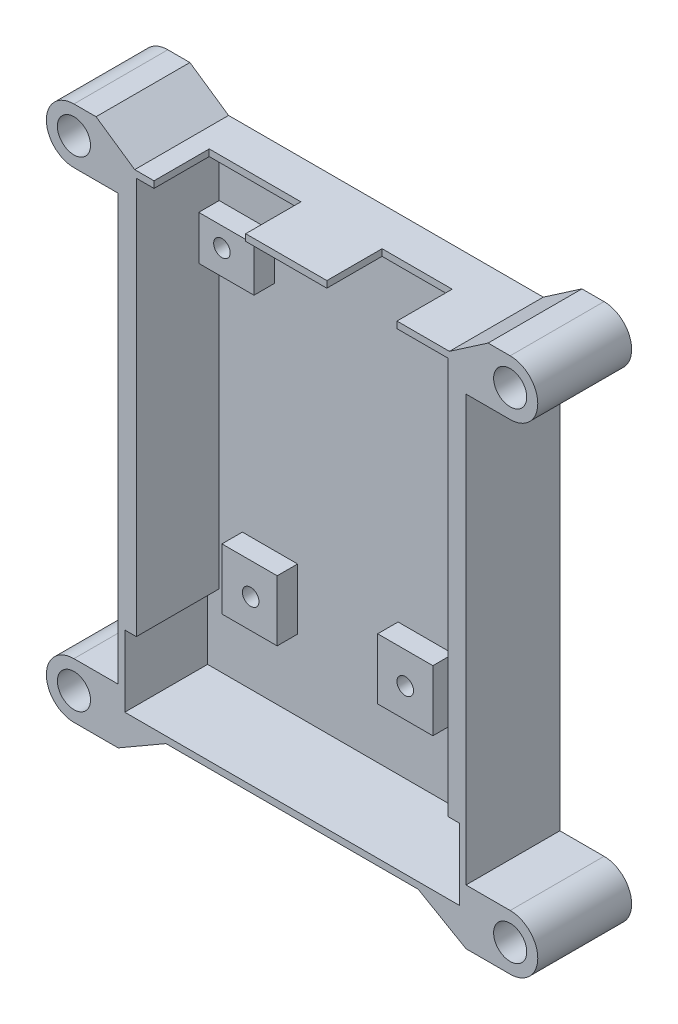
from build123d import *

# Parameters (mm, degrees)
EXTRUDE_1_DEPTH          = 2
SKETCH_2_W               = 56.4
SKETCH_2_H               = 71.9
EXTRUDE_3_DEPTH          = 15
SKETCH_6_R               = 3
CUT_EXTRUDE_1_DEPTH      = 18
SKETCH_7_W               = 10
SKETCH_7_H               = 8
SKETCH_7_H_2             = 11
EXTRUDE_4_DEPTH          = 3.7
SKETCH_8_R               = 1.5
CUT_EXTRUDE_2_DEPTH      = 6.7
CUT_EXTRUDE_5_DEPTH      = 1
CUT_EXTRUDE_5_DEPTH_BACK = 18
SKETCH_14_W              = 60.6
SKETCH_14_H              = 12.9
CUT_EXTRUDE_10_DEPTH     = 15
SKETCH_10_W              = 16.6
SKETCH_10_H              = 10
SKETCH_10_W_2            = 12.7
CUT_EXTRUDE_12_DEPTH     = 10
SKETCH_15_R              = 2.8
CUT_EXTRUDE_15_DEPTH     = 2.4


with BuildPart() as part:
    # 草图1 → 凸台-拉伸1 (new body)
    with BuildSketch(Plane.XY):
        with BuildLine():
            Line((0, 0), (8, 0))
            Line((8, 0), (8, 77))
            Line((8, 77), (0, 77))
            ThreePointArc((0, 77), (-5, 82), (0, 87))
            Line((0, 87), (79, 87))
            ThreePointArc((79, 87), (84, 82), (79, 77))
            Line((79, 77), (71, 77))
            Line((71, 77), (71, 0))
            Line((71, 0), (79, 0))
            ThreePointArc((79, 0), (84, -5), (79, -10))
            Line((79, -10), (71, -10))
            Line((71, -10), (62.339745962, -5))
            Line((62.339745962, -5), (16.660254038, -5))
            Line((16.660254038, -5), (8, -10))
            Line((8, -10), (0, -10))
            ThreePointArc((0, -10), (-5, -5), (0, 0))
        make_face()
    extrude(amount=EXTRUDE_1_DEPTH)

    # 草图2 → 凸台-拉伸3 (add)
    with BuildSketch(Plane.XY.offset(2)):
        with BuildLine():
            Line((8, 0), (0, 0))
            ThreePointArc((0, 0), (-5, -5), (0, -10))
            Line((0, -10), (8, -10))
            Line((8, -10), (16.660254038, -5))
            Line((16.660254038, -5), (62.339745962, -5))
            Line((62.339745962, -5), (71, -10))
            Line((71, -10), (79, -10))
            ThreePointArc((79, -10), (84, -5), (79, 0))
            Line((79, 0), (71, 0))
            Line((71, 0), (71, 77))
            Line((71, 77), (79, 77))
            ThreePointArc((79, 77), (84, 82), (79, 87))
            Line((79, 87), (0, 87))
            ThreePointArc((0, 87), (-5, 82), (0, 77))
            Line((0, 77), (8, 77))
            Line((8, 77), (8, 0))
        make_face()
        with Locations((39.5, 45.05)):
            Rectangle(SKETCH_2_W, SKETCH_2_H, mode=Mode.SUBTRACT)
    extrude(amount=EXTRUDE_3_DEPTH)

    # 草图6 → 切除-拉伸1 (cut, through all)
    with BuildSketch(Plane.XY.offset(17)):
        with Locations((0, 82)):
            Circle(SKETCH_6_R)
        with Locations((0, -5)):
            Circle(SKETCH_6_R)
        with Locations((79, -5)):
            Circle(SKETCH_6_R)
        with Locations((79, 82)):
            Circle(SKETCH_6_R)
    extrude(amount=-CUT_EXTRUDE_1_DEPTH, mode=Mode.SUBTRACT)

    # 草图7 → 凸台-拉伸4 (add)
    with BuildSketch(Plane.XY.offset(2)):
        with Locations((62.7, 65.8)):
            Rectangle(SKETCH_7_W, SKETCH_7_H)
        with Locations((16.3, 66)):
            Rectangle(SKETCH_7_W, SKETCH_7_H)
        with Locations((48.7, 14.6)):
            Rectangle(SKETCH_7_W, SKETCH_7_H_2)
        with Locations((20.5, 14.6)):
            Rectangle(SKETCH_7_W, SKETCH_7_H_2)
    extrude(amount=EXTRUDE_4_DEPTH)

    # 草图8 → 切除-拉伸2 (cut, through all)
    with BuildSketch(Plane.XY.offset(5.7)):
        with Locations((63.7, 65.2)):
            Circle(SKETCH_8_R)
        with Locations((15.5, 66.5)):
            Circle(SKETCH_8_R)
        with Locations((20.7, 14.4)):
            Circle(SKETCH_8_R)
        with Locations((48.7, 14.4)):
            Circle(SKETCH_8_R)
    extrude(amount=-CUT_EXTRUDE_2_DEPTH, mode=Mode.SUBTRACT)

    # 草图11 → 切除-拉伸5 (cut, two sides)
    with BuildSketch(Plane.XY.offset(17)) as cut_extrude_5_sk:
        Polygon((-211.639949222, 234.867393752), (4, 87), (11, 82.2), (68, 82.2), (75, 87), (290.639949222, 234.867393752), (290.639949222, 757.802777275), (-211.639949222, 757.802777275), align=None)
    extrude(amount=CUT_EXTRUDE_5_DEPTH, mode=Mode.SUBTRACT)
    extrude(cut_extrude_5_sk.sketch, amount=-CUT_EXTRUDE_5_DEPTH_BACK, mode=Mode.SUBTRACT)

    # 草图14 → 切除-拉伸10 (cut)
    with BuildSketch(Plane.XY.offset(17)):
        with Locations((39.5, 2.65)):
            Rectangle(SKETCH_14_W, SKETCH_14_H)
    extrude(amount=-CUT_EXTRUDE_10_DEPTH, mode=Mode.SUBTRACT)

    # 草图10 → 切除-拉伸12 (cut)
    with BuildSketch(Plane.XZ.offset(-81)):
        with Locations((22.8, 12)):
            Rectangle(SKETCH_10_W, SKETCH_10_H)
        with Locations((52.15, 12)):
            Rectangle(SKETCH_10_W_2, SKETCH_10_H)
    extrude(amount=-CUT_EXTRUDE_12_DEPTH, mode=Mode.SUBTRACT)

    # 草图15 → 切除-拉伸15 (cut)
    with BuildSketch(Plane(origin=(0, 0, 0), x_dir=(-1, 0, 0), z_dir=(0, 0, -1))):
        with Locations((-15.5, 66.5)):
            Circle(SKETCH_15_R)
        with Locations((-20.7, 14.4)):
            Circle(SKETCH_15_R)
        with Locations((-48.7, 14.4)):
            Circle(SKETCH_15_R)
        with Locations((-63.7, 65.2)):
            Circle(SKETCH_15_R)
    extrude(amount=-CUT_EXTRUDE_15_DEPTH, mode=Mode.SUBTRACT)


solid = part.part
